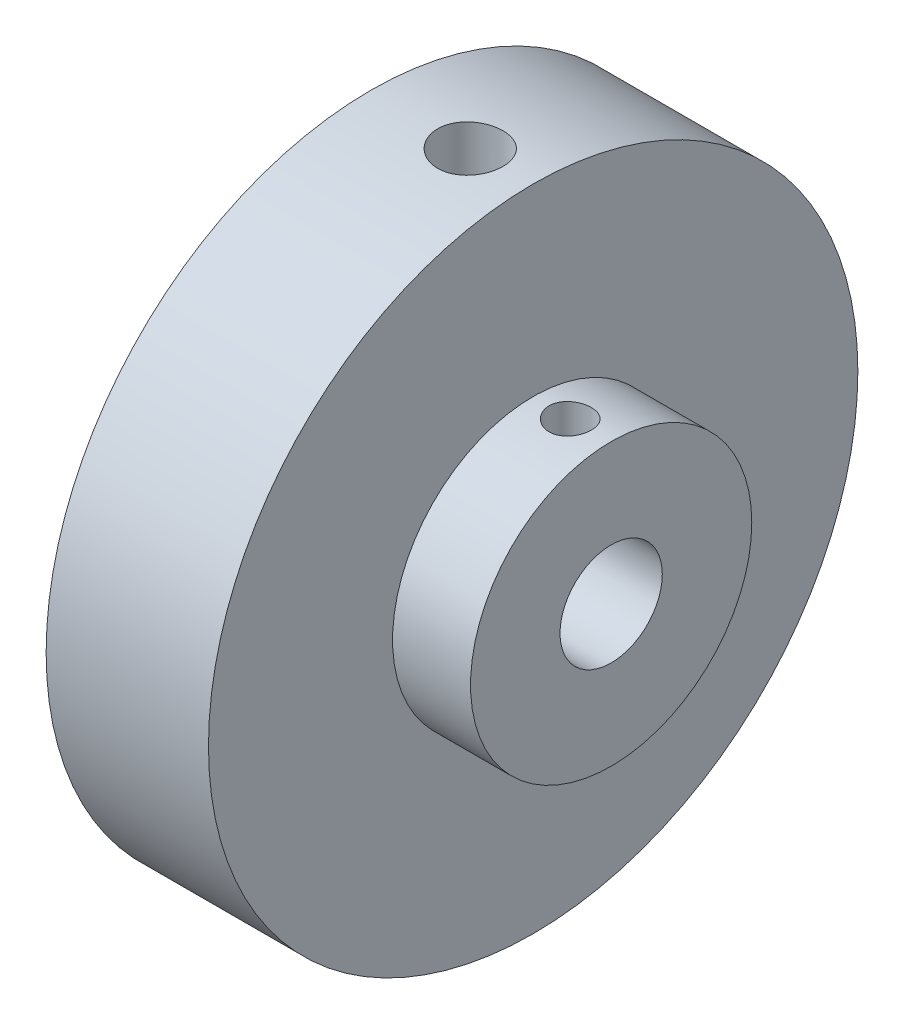
from build123d import *

# Parameters (mm, degrees)
SKETCH2_R                 = 11
BOSS_EXTRUDE2_DEPTH       = 6.1
SKETCH7_R                 = 4
CUT_EXTRUDE3_DEPTH        = 7.1
SKETCH8_R                 = 25.4
BOSS_EXTRUDE3_DEPTH       = 12.7
SKETCH10_R                = 4
CUT_EXTRUDE5_DEPTH        = 13.7
F_1_4_20_TAPPED_HOLE1_D   = 5.1054
M4X0_7_TAPPED_HOLE2_D     = 3.3
M4X0_7_TAPPED_HOLE2_DEPTH = 11.176
M4X0_7_TAPPED_HOLE2_TIP   = 0.991420021


with BuildPart() as part:
    # Sketch2 → Boss-Extrude2 (new body)
    with BuildSketch(Plane(origin=(0, 0, 0), x_dir=(0, 0, -1), z_dir=(1, 0, 0))):
        Circle(SKETCH2_R)
    extrude(amount=BOSS_EXTRUDE2_DEPTH)

    # Sketch7 → Cut-Extrude3 (cut, through all)
    with BuildSketch(Plane(origin=(6.1, 0, 0), x_dir=(0, 0, -1), z_dir=(1, 0, 0))):
        Circle(SKETCH7_R)
    extrude(amount=-CUT_EXTRUDE3_DEPTH, mode=Mode.SUBTRACT)

    # Sketch8 → Boss-Extrude3 (add)
    with BuildSketch(Plane.ZY):
        Circle(SKETCH8_R)
    extrude(amount=BOSS_EXTRUDE3_DEPTH)

    # Sketch10 → Cut-Extrude5 (cut, through all)
    with BuildSketch(Plane(origin=(0, 0, 0), x_dir=(0, 0, -1), z_dir=(1, 0, 0))):
        Circle(SKETCH10_R)
    extrude(amount=-CUT_EXTRUDE5_DEPTH, mode=Mode.SUBTRACT)

    # 1/4-20 Tapped Hole1 (through all)
    with Locations(Plane(origin=(-4.921208149, 25.4, 0), x_dir=(0, 0, 1), z_dir=(0, 1, 0))):
        with Locations((0, 0)):
            Hole(F_1_4_20_TAPPED_HOLE1_D / 2)

    # M4x0.7 Tapped Hole2
    with Locations(Plane(origin=(2.900798662, 11, 0), x_dir=(0, 0, 1), z_dir=(0, 1, 0))):
        with Locations((0, 0)):
            Hole(M4X0_7_TAPPED_HOLE2_D / 2, depth=M4X0_7_TAPPED_HOLE2_DEPTH)
            with Locations((0, 0, -(M4X0_7_TAPPED_HOLE2_DEPTH + M4X0_7_TAPPED_HOLE2_TIP / 2))):  # 118° drill point
                Cone(0, M4X0_7_TAPPED_HOLE2_D / 2, M4X0_7_TAPPED_HOLE2_TIP, mode=Mode.SUBTRACT)


solid = part.part
